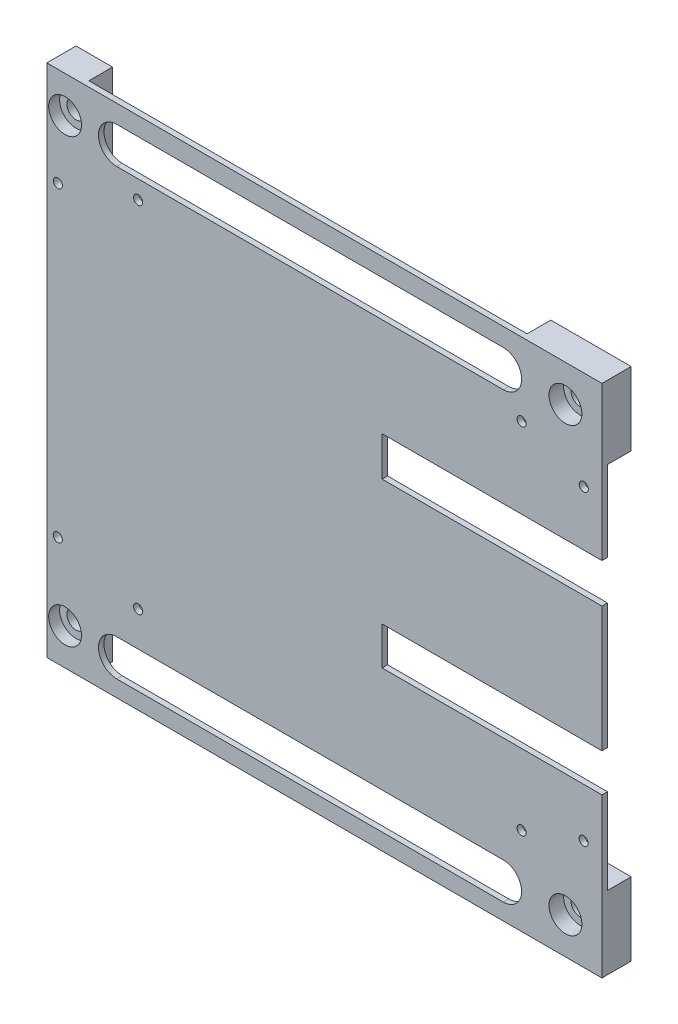
from build123d import *

# Parameters (mm, degrees)
SKETCH1_W           = 10
SKETCH1_H           = 141
BOSS_EXTRUDE1_DEPTH = 8
SKETCH2_R           = 2.5
CUT_EXTRUDE1_DEPTH  = 8
SKETCH3_W           = 142
SKETCH3_H           = 141
BOSS_EXTRUDE2_DEPTH = 1.5
CUT_EXTRUDE4_DEPTH  = 24
SKETCH12_W          = 60
SKETCH12_H          = 10.777657791
SKETCH12_H_2        = 10.436358021
CUT_EXTRUDE6_DEPTH  = 10
SKETCH14_W          = 22
SKETCH14_H          = 20
BOSS_EXTRUDE5_DEPTH = 6.5
SKETCH16_W          = 61.380351881
SKETCH16_H          = 10.777657791
SKETCH16_H_2        = 10.440898972
CUT_EXTRUDE9_DEPTH  = 26.5
SKETCH17_R          = 4.5
CUT_EXTRUDE10_DEPTH = 3
SKETCH9_R           = 1.25
CUT_EXTRUDE11_DEPTH = 14
SKETCH13_R          = 2.5
CUT_EXTRUDE12_DEPTH = 14
SKETCH19_R          = 4.5
CUT_EXTRUDE13_DEPTH = 4
SKETCH20_R          = 1.25
CUT_EXTRUDE14_DEPTH = 4


with BuildPart() as part:
    # Sketch1 → Boss-Extrude1 (new body)
    with BuildSketch(Plane.XY):
        with Locations((5, 70.5)):
            Rectangle(SKETCH1_W, SKETCH1_H)
    extrude(amount=BOSS_EXTRUDE1_DEPTH)

    # Sketch2 → Cut-Extrude1 (cut)
    with BuildSketch(Plane.XY.offset(8)):
        with Locations((5, 131)):
            Circle(SKETCH2_R)
        with Locations((5, 10)):
            Circle(SKETCH2_R)
    extrude(amount=-CUT_EXTRUDE1_DEPTH, mode=Mode.SUBTRACT)

    # Sketch3 → Boss-Extrude2 (add)
    with BuildSketch(Plane.XY.offset(8)):
        with Locations((81, 70.5)):
            Rectangle(SKETCH3_W, SKETCH3_H)
    extrude(amount=-BOSS_EXTRUDE2_DEPTH)

    # Sketch8 → Cut-Extrude4 (cut)
    with BuildSketch(Plane.XY.offset(8)):
        with BuildLine():
            Line((19.143151415, 136), (125, 136))
            ThreePointArc((125, 136), (130, 131), (125, 126))
            Line((125, 126), (19.143151415, 126))
            ThreePointArc((19.143151415, 126), (14.143151415, 131), (19.143151415, 136))
        make_face()
        with BuildLine():
            Line((19.143151415, 14.495923054), (125, 14.495923054))
            ThreePointArc((125, 14.495923054), (130, 9.495923054), (125, 4.495923054))
            Line((125, 4.495923054), (19.143151415, 4.495923054))
            ThreePointArc((19.143151415, 4.495923054), (14.143151415, 9.495923054), (19.143151415, 14.495923054))
        make_face()
    extrude(amount=-CUT_EXTRUDE4_DEPTH, mode=Mode.SUBTRACT)

    # Sketch12 → Cut-Extrude6 (cut)
    with BuildSketch(Plane.XY.offset(8)):
        with Locations((121.8, 93.584876831)):
            Rectangle(SKETCH12_W, SKETCH12_H)
        with Locations((121.8, 48.647743856)):
            Rectangle(SKETCH12_W, SKETCH12_H_2)
    extrude(amount=-CUT_EXTRUDE6_DEPTH, mode=Mode.SUBTRACT)

    # Sketch14 → Boss-Extrude5 (add)
    with BuildSketch(Plane(origin=(0, 0, 6.5), x_dir=(-1, 0, 0), z_dir=(0, 0, -1))):
        with Locations((-141, 131)):
            Rectangle(SKETCH14_W, SKETCH14_H)
        with Locations((-141, 10)):
            Rectangle(SKETCH14_W, SKETCH14_H)
    extrude(amount=BOSS_EXTRUDE5_DEPTH)

    # Sketch16 → Cut-Extrude9 (cut)
    with BuildSketch(Plane.XY.offset(8)):
        with Locations((122.490175941, 93.584876831)):
            Rectangle(SKETCH16_W, SKETCH16_H)
        with Locations((122.490175941, 48.64547338)):
            Rectangle(SKETCH16_W, SKETCH16_H_2)
    extrude(amount=-CUT_EXTRUDE9_DEPTH, mode=Mode.SUBTRACT)

    # Sketch17 → Cut-Extrude10 (cut)
    with BuildSketch(Plane.XY.offset(8)):
        with Locations((5, 131)):
            Circle(SKETCH17_R)
        with Locations((5, 10)):
            Circle(SKETCH17_R)
    extrude(amount=-CUT_EXTRUDE10_DEPTH, mode=Mode.SUBTRACT)

    # Sketch9 → Cut-Extrude11 (cut)
    with BuildSketch(Plane.XY.offset(8)):
        with Locations((147.028762267, 114.00755189)):
            Circle(SKETCH9_R)
        with Locations((3.027444188, 114)):
            Circle(SKETCH9_R)
        with Locations((3, 30.019439847)):
            Circle(SKETCH9_R)
        with Locations((147, 30.019439847)):
            Circle(SKETCH9_R)
    extrude(amount=-CUT_EXTRUDE11_DEPTH, mode=Mode.SUBTRACT)

    # Sketch13 → Cut-Extrude12 (cut)
    with BuildSketch(Plane.XY.offset(8)):
        with Locations((142, 131)):
            Circle(SKETCH13_R)
        with Locations((142, 10)):
            Circle(SKETCH13_R)
    extrude(amount=-CUT_EXTRUDE12_DEPTH, mode=Mode.SUBTRACT)

    # Sketch19 → Cut-Extrude13 (cut)
    with BuildSketch(Plane.XY.offset(8)):
        with Locations((142, 131)):
            Circle(SKETCH19_R)
        with Locations((142, 10)):
            Circle(SKETCH19_R)
    extrude(amount=-CUT_EXTRUDE13_DEPTH, mode=Mode.SUBTRACT)

    # Sketch20 → Cut-Extrude14 (cut)
    with BuildSketch(Plane.XY.offset(8)):
        with Locations((25, 121)):
            Circle(SKETCH20_R)
        with Locations((130, 121)):
            Circle(SKETCH20_R)
        with Locations((130, 24)):
            Circle(SKETCH20_R)
        with Locations((25, 24)):
            Circle(SKETCH20_R)
    extrude(amount=-CUT_EXTRUDE14_DEPTH, mode=Mode.SUBTRACT)


solid = part.part
